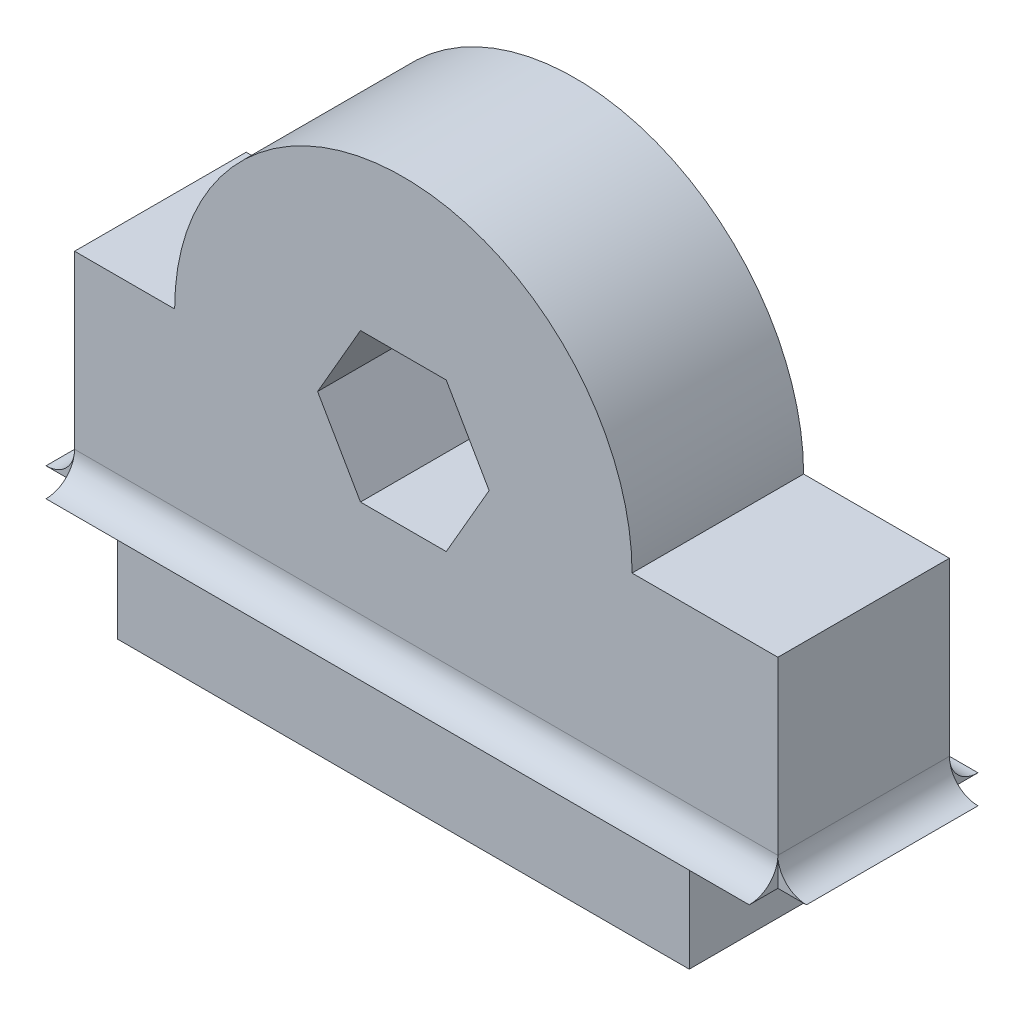
from build123d import *

# Parameters (mm, degrees)
BOSS_EXTRUDE1_DEPTH = 6
BOSS_EXTRUDE2_DEPTH = 24.6
BOSS_EXTRUDE3_DEPTH = 6


with BuildPart() as part:
    # Sketch1 → Boss-Extrude1 (new body)
    with BuildSketch(Plane.XY):
        with BuildLine():
            Line((0, 0), (20, 0))
            Line((20, 0), (20, 4))
            Line((20, 4), (23.1, 4))
            Line((23.1, 4), (23.1, 11))
            Line((23.1, 11), (18, 11))
            ThreePointArc((18, 11), (10, 19), (2, 11))
            Line((2, 11), (-1.5, 11))
            Line((-1.5, 11), (-1.5, 4))
            Line((-1.5, 4), (0, 4))
            Line((0, 4), (0, 0))
        make_face()
        Polygon((13, 11), (11.5, 13.598076211), (8.5, 13.598076211), (7, 11), (8.5, 8.401923789), (11.5, 8.401923789), align=None, mode=Mode.SUBTRACT)
    extrude(amount=BOSS_EXTRUDE1_DEPTH)

    # Sketch2 → Boss-Extrude2 (add)
    with BuildSketch(Plane.ZY.offset(1.5)):
        with BuildLine():
            Line((6, 4), (6, 5))
            ThreePointArc((6, 5), (6.292893219, 4.292893219), (7, 4))
            Line((7, 4), (6, 4))
        make_face()
        with BuildLine():
            Line((0, 4), (-1, 4))
            ThreePointArc((-1, 4), (-0.292893219, 4.292893219), (0, 5))
            Line((0, 5), (0, 4))
        make_face()
    extrude(amount=-BOSS_EXTRUDE2_DEPTH)

    # Sketch4 → Boss-Extrude3 (add)
    with BuildSketch(Plane.XY.offset(6)):
        with BuildLine():
            Line((23.1, 4), (23.1, 5))
            ThreePointArc((23.1, 5), (23.392893219, 4.292893219), (24.1, 4))
            Line((24.1, 4), (23.1, 4))
        make_face()
        with BuildLine():
            Line((-1.5, 4), (-2.5, 4))
            ThreePointArc((-2.5, 4), (-1.792893219, 4.292893219), (-1.5, 5))
            Line((-1.5, 5), (-1.5, 4))
        make_face()
    extrude(amount=-BOSS_EXTRUDE3_DEPTH)


solid = part.part
